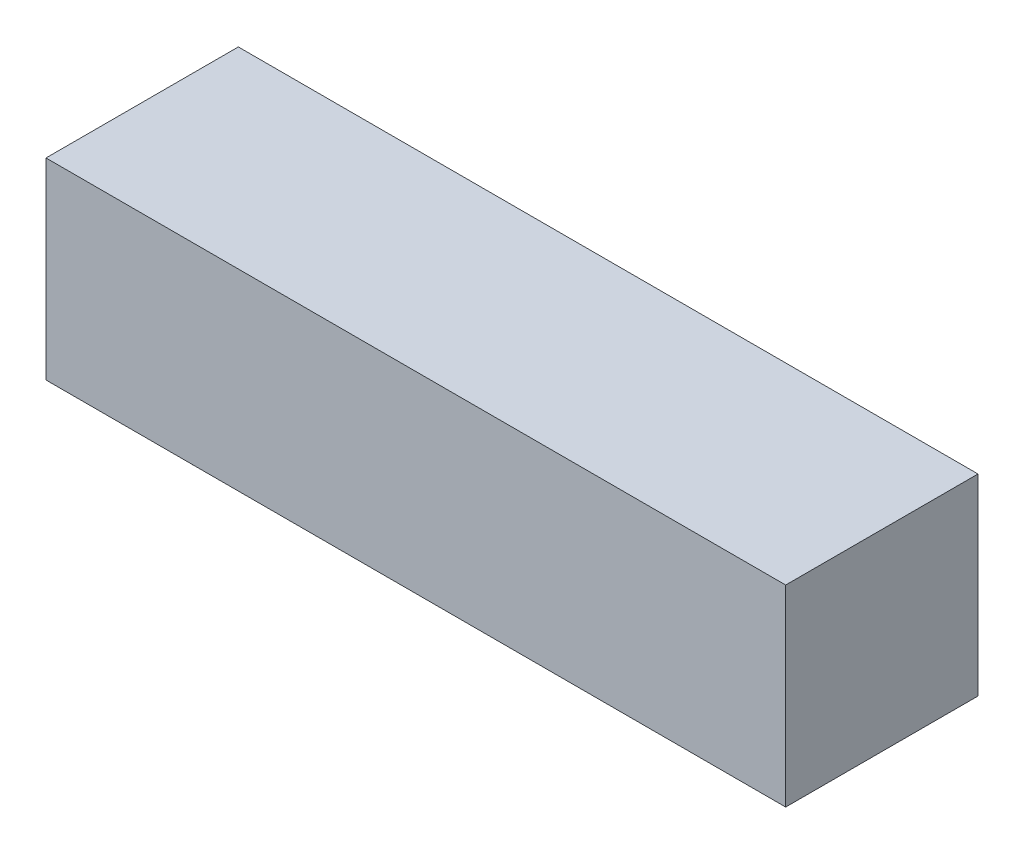
from build123d import *

# Parameters (mm, degrees)
ESQUISSE1_W        = 50
ESQUISSE1_H        = 13
BOSS_EXTRU_1_DEPTH = 13


with BuildPart() as part:
    # Esquisse1 → Boss.-Extru.1 (new body)
    with BuildSketch(Plane.XY):
        with Locations((2.300170949, 4.811023622)):
            Rectangle(ESQUISSE1_W, ESQUISSE1_H)
    extrude(amount=BOSS_EXTRU_1_DEPTH)


solid = part.part
